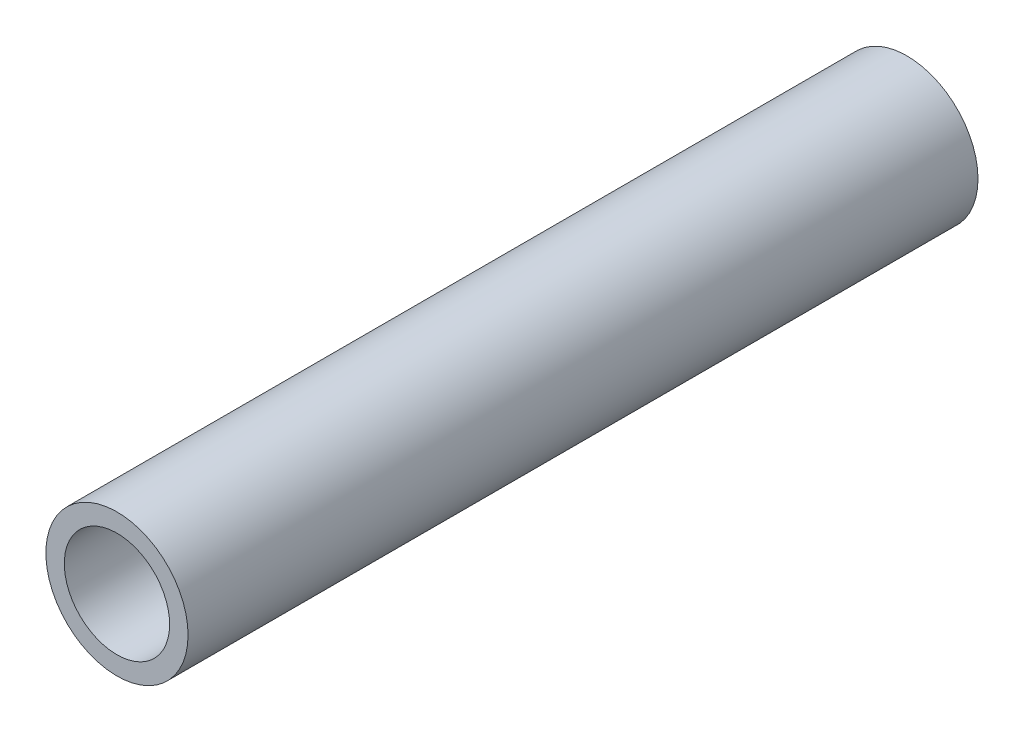
from build123d import *

# Parameters (mm, degrees)
SKETCH1_R           = 1.35
SKETCH1_R_2         = 1
BOSS_EXTRUDE1_DEPTH = 15


with BuildPart() as part:
    # Sketch1 → Boss-Extrude1 (new body)
    with BuildSketch(Plane.XY):
        Circle(SKETCH1_R)
        Circle(SKETCH1_R_2, mode=Mode.SUBTRACT)
    extrude(amount=BOSS_EXTRUDE1_DEPTH)


solid = part.part
